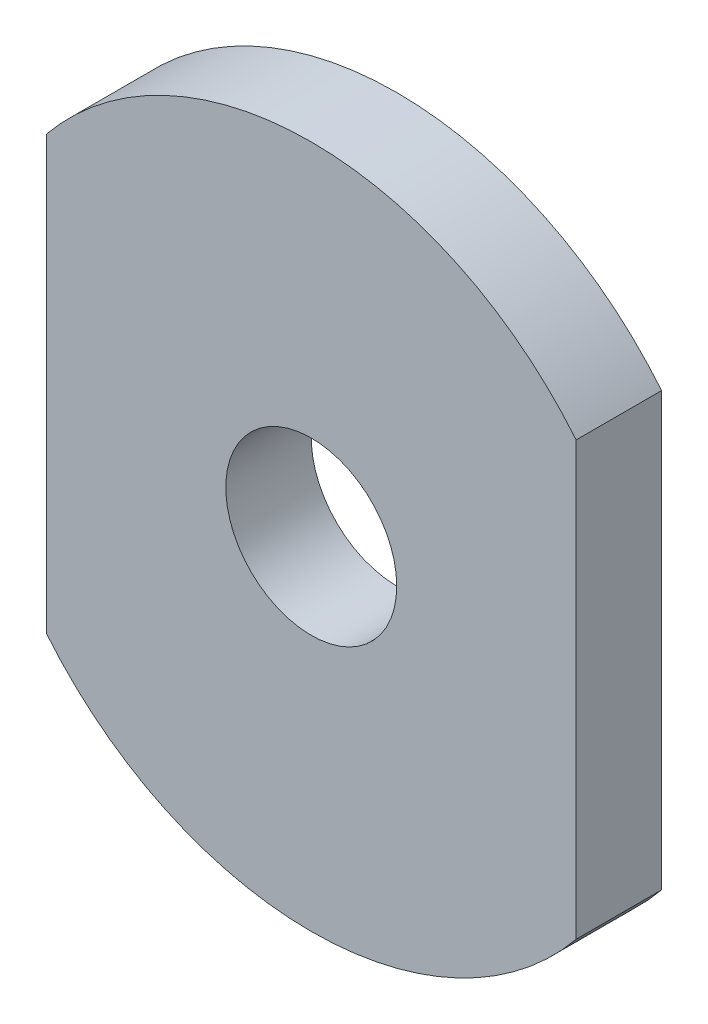
from build123d import *

# Parameters (mm, degrees)
SKETCH1_R           = 5
BOSS_EXTRUDE1_DEPTH = 5


with BuildPart() as part:
    # Sketch1 → Boss-Extrude1 (new body)
    with BuildSketch(Plane.XY):
        with BuildLine():
            Line((-15.492752905, 12.648106871), (-15.492752905, -12.648106871))
            ThreePointArc((-15.492752905, -12.648106871), (0, -20), (15.492752905, -12.648106871))
            Line((15.492752905, -12.648106871), (15.492752905, 12.648106871))
            ThreePointArc((15.492752905, 12.648106871), (0, 20), (-15.492752905, 12.648106871))
        make_face()
        Circle(SKETCH1_R, mode=Mode.SUBTRACT)
    extrude(amount=BOSS_EXTRUDE1_DEPTH)


solid = part.part
